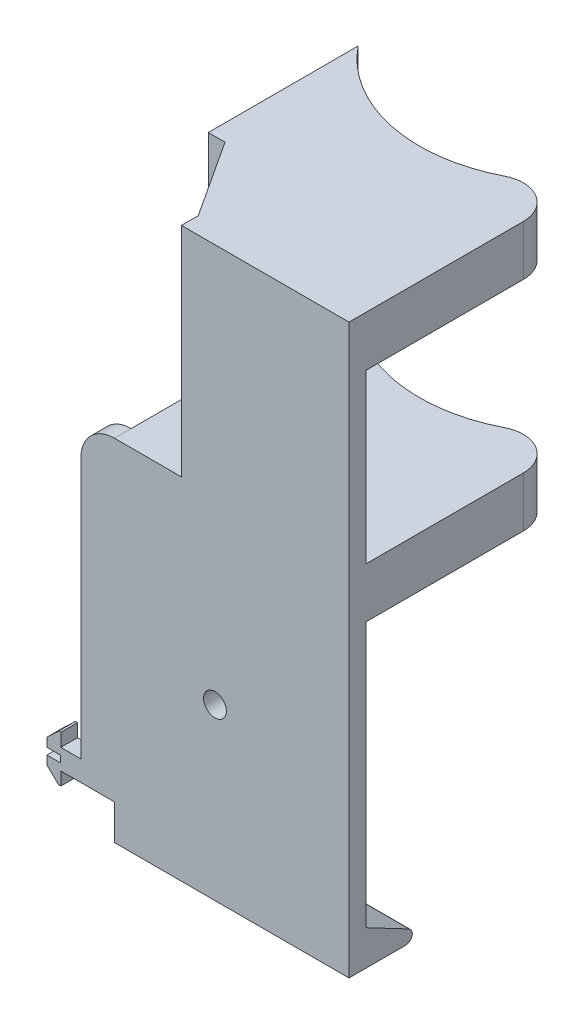
from build123d import *

# Parameters (mm, degrees)
BOSS_EXTRUDE1_DEPTH = 5
BOSS_EXTRUDE2_DEPTH = 80
SKETCH4_W           = 4
SKETCH4_H           = 2
CUT_EXTRUDE1_DEPTH  = 73.715728753
SKETCH5_W           = 67.715728753
SKETCH5_H           = 50
CUT_EXTRUDE2_DEPTH  = 81
CUT_EXTRUDE3_DEPTH  = 65
SKETCH7_W           = 80
SKETCH7_H           = 5
BOSS_EXTRUDE3_DEPTH = 10.5
BOSS_EXTRUDE4_DEPTH = 80
FILLET1_R           = 2
FILLET2_R           = 10
CUT_EXTRUDE4_DEPTH  = 170.5
FILLET3_R           = 10
SKETCH10_R          = 3.4
CUT_EXTRUDE5_DEPTH  = 6


with BuildPart() as part:
    # Sketch2 → Boss-Extrude1 (new body)
    with BuildSketch(Plane.XY):
        Polygon((-5.152414984, 3.618325464), (-5.152414984, -3.618325464), (-1.641080211, -6.95), (-1, -6.95), (-1, -3.05), (95, -3.05), (95, 155.95), (5, 155.95), (5, 3.05), (-1, 3.05), (-1, 6.95), (-1.641080211, 6.95), align=None)
    extrude(amount=-BOSS_EXTRUDE1_DEPTH)

    # Sketch3 → Boss-Extrude2 (add)
    with BuildSketch(Plane(origin=(0, 155.95, 0), x_dir=(1, 0, 0), z_dir=(0, 1, 0))):
        with BuildLine():
            ThreePointArc((85, 72.715728753), (50, 56), (15, 72.715728753))
            Line((15, 72.715728753), (15, 5))
            Line((15, 5), (85, 5))
            Line((85, 5), (85, 72.715728753))
        make_face()
    extrude(amount=-BOSS_EXTRUDE2_DEPTH)

    # Sketch4 → Cut-Extrude1 (cut, through all)
    with BuildSketch(Plane.XY):
        with Locations((-3.152414984, 0)):
            Rectangle(SKETCH4_W, SKETCH4_H)
    extrude(amount=-CUT_EXTRUDE1_DEPTH, mode=Mode.SUBTRACT)

    # Sketch5 → Cut-Extrude2 (cut, through all)
    with BuildSketch(Plane.ZY.offset(-15)):
        with Locations((-38.857864377, 115.95)):
            Rectangle(SKETCH5_W, SKETCH5_H)
    extrude(amount=-CUT_EXTRUDE2_DEPTH, mode=Mode.SUBTRACT)

    # Sketch6 → Cut-Extrude3 (cut)
    with BuildSketch(Plane(origin=(0, 155.95, 0), x_dir=(1, 0, 0), z_dir=(0, 1, 0))):
        Polygon((35, 0), (35, 5), (20, 28), (15, 28), (15, 5), (5, 5), (5, 0), align=None)
    extrude(amount=-CUT_EXTRUDE3_DEPTH, mode=Mode.SUBTRACT)

    # Sketch7 → Boss-Extrude3 (add)
    with BuildSketch(Plane.XZ.offset(3.05)):
        with Locations((55, -2.5)):
            Rectangle(SKETCH7_W, SKETCH7_H)
    extrude(amount=BOSS_EXTRUDE3_DEPTH)

    # Sketch8 → Boss-Extrude4 (add)
    with BuildSketch(Plane.ZY.offset(-15)):
        Polygon((-5, -3.05), (-25, -13.55), (-5, -13.55), align=None)
    extrude(amount=-BOSS_EXTRUDE4_DEPTH)

    # Fillet1
    fillet1_edges = [part.edges().sort_by_distance(p)[0] for p in [
        (55, -13.55, -25),
    ]]
    fillet(fillet1_edges, radius=FILLET1_R)

    # Fillet2
    fillet2_edges = [part.edges().sort_by_distance(p)[0] for p in [
        (5, 90.95, -2.5),
    ]]
    fillet(fillet2_edges, radius=FILLET2_R)

    # Sketch9 → Cut-Extrude4 (cut, through all)
    with BuildSketch(Plane(origin=(0, 155.95, 0), x_dir=(1, 0, 0), z_dir=(0, 1, 0))):
        Polygon((85, 5), (85, 0), (95, 0), (95, 72.715728753), (85, 72.715728753), align=None)
    extrude(amount=-CUT_EXTRUDE4_DEPTH, mode=Mode.SUBTRACT)

    # Fillet3
    fillet3_edges = [part.edges().sort_by_distance(p)[0] for p in [
        (85, 83.45, -72.715728753),
        (85, 148.45, -72.715728753),
    ]]
    fillet(fillet3_edges, radius=FILLET3_R)

    # Sketch10 → Cut-Extrude5 (cut, through all)
    with BuildSketch(Plane(origin=(0, 0, -5), x_dir=(-1, 0, 0), z_dir=(0, 0, -1))):
        with Locations((-45, 37.07686976)):
            Circle(SKETCH10_R)
    extrude(amount=-CUT_EXTRUDE5_DEPTH, mode=Mode.SUBTRACT)


solid = part.part
